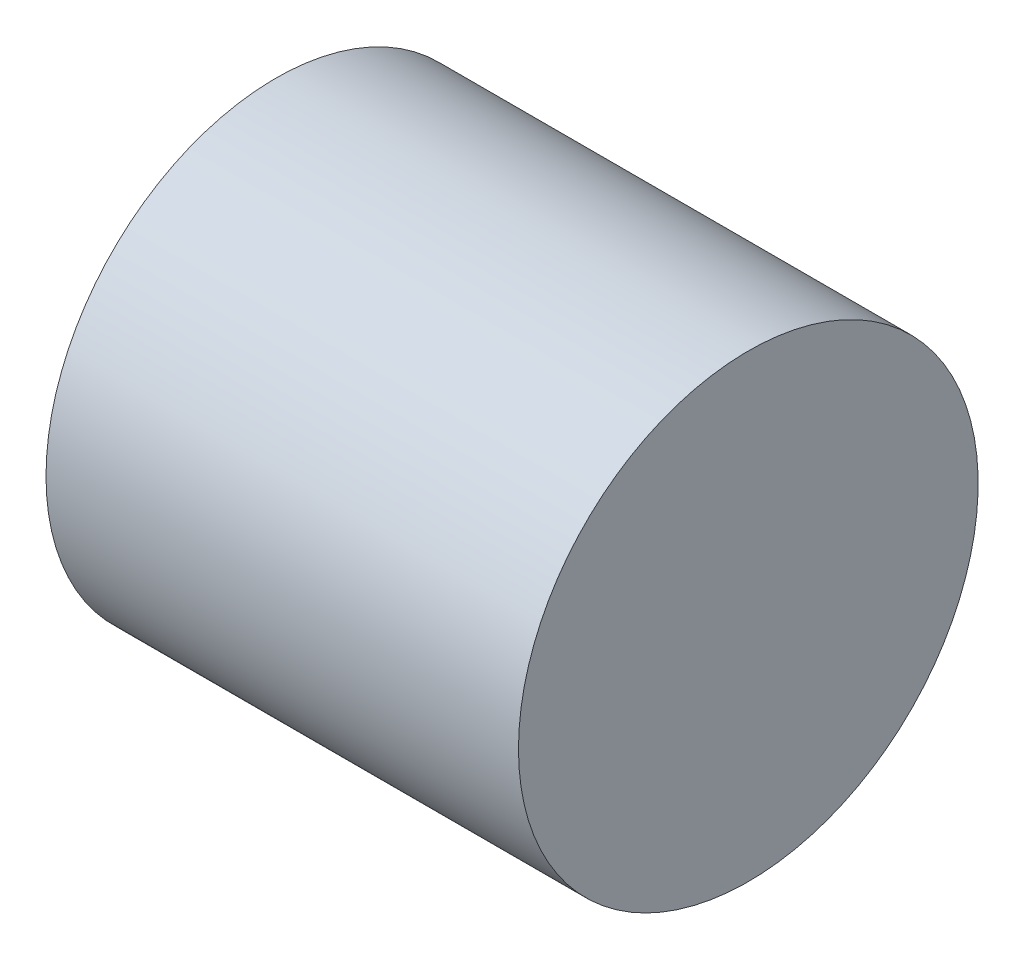
from build123d import *

# Parameters (mm, degrees)
SCALE1_SCALE = 50


with BuildPart() as part:
    # Sketch1 → Revolve1 (revolve)
    with BuildSketch(Plane.XY):
        Polygon((17.685185185, 0), (17.685185185, 18), (-19.314814815, 18), (-19.314814815, 1), (-17.314814815, 1), (-17.314814815, 0), align=None)
    revolve(axis=Axis((-19.537037037, 0, 0), (1, 0, 0)))


with BuildPart() as part_1:
    # Scale1: scaled about (-0.811894741, 0, 0)
    add(part.part.scale(SCALE1_SCALE).moved(Location((39.782842309, 0, 0))))


solid = part_1.part
